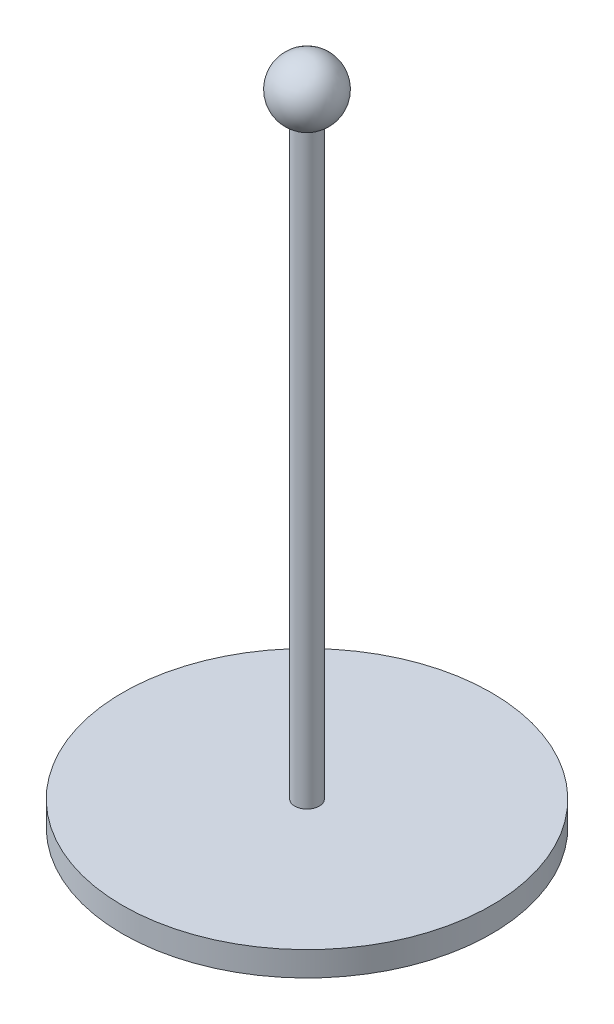
from build123d import *

# Parameters (mm, degrees)
ESBO_O1_R                = 75
RESSALTO_EXTRUS_O1_DEPTH = 10
ESBO_O2_R                = 5
RESSALTO_EXTRUS_O2_DEPTH = 250


with BuildPart() as part:
    # Esboço1 → Ressalto-extrusão1 (new body)
    with BuildSketch(Plane(origin=(0, 0, 0), x_dir=(1, 0, 0), z_dir=(0, 1, 0))):
        Circle(ESBO_O1_R)
    extrude(amount=RESSALTO_EXTRUS_O1_DEPTH)

    # Esboço2 → Ressalto-extrusão2 (add)
    with BuildSketch(Plane(origin=(0, 10, 0), x_dir=(1, 0, 0), z_dir=(0, 1, 0))):
        Circle(ESBO_O2_R)
    extrude(amount=RESSALTO_EXTRUS_O2_DEPTH)

    # Esboço4 → Revolução1 (revolve)
    with BuildSketch(Plane(origin=(0, 0, 0), x_dir=(0, 0, -1), z_dir=(1, 0, 0))):
        with BuildLine():
            Line((0, 272.5), (0, 247.5))
            ThreePointArc((0, 247.5), (12.5, 260), (0, 272.5))
        make_face()
    revolve(axis=Axis((0, 272.5, 0), (0, -1, 0)))


solid = part.part
